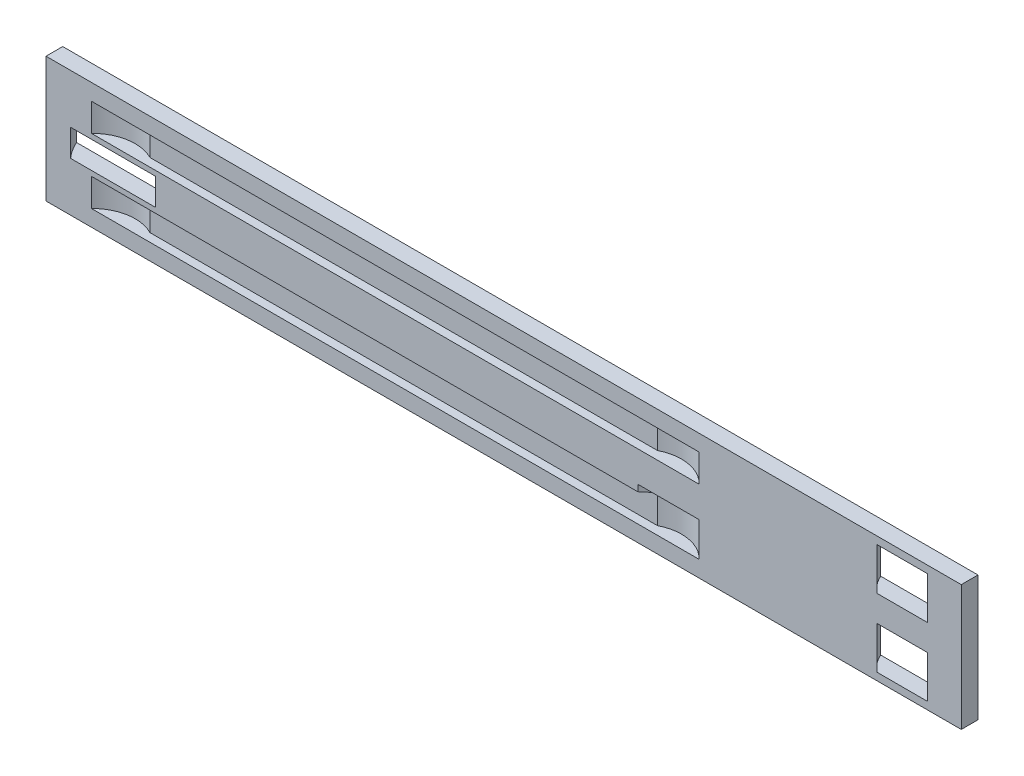
from build123d import *

# Parameters (mm, degrees)
CROQUIS1_W              = 985
CROQUIS1_H              = 135
SALIENTE_EXTRUIR1_DEPTH = 18
CROQUIS2_R              = 45
CORTAR_EXTRUIR1_DEPTH   = 45.5
CROQUIS4_R              = 62.2
CORTAR_EXTRUIR2_DEPTH   = 14.5
CORTAR_EXTRUIR3_DEPTH   = 15
CROQUIS7_R              = 46
CORTAR_EXTRUIR4_DEPTH   = 7


with BuildPart() as part:
    # Croquis1 → Saliente-Extruir1 (new body)
    with BuildSketch(Plane.XY):
        with Locations((492.5, 67.5)):
            Rectangle(CROQUIS1_W, CROQUIS1_H)
    extrude(amount=SALIENTE_EXTRUIR1_DEPTH)

    # Croquis2 → Cortar-Extruir1 (cut)
    with BuildSketch(Plane(origin=(0, 8, 0), x_dir=(-1, 0, 0), z_dir=(0, -1, 0))):
        with Locations((-921.5, 18)):
            Circle(CROQUIS2_R)
    cortar_extruir1 = extrude(amount=-CORTAR_EXTRUIR1_DEPTH, mode=Mode.SUBTRACT)

    # Simetría1: Cortar-Extruir1 across plane
    add(cortar_extruir1.mirror(Plane.ZX.offset(67.5)), mode=Mode.SUBTRACT)

    # Croquis4 → Cortar-Extruir2 (cut, symmetric)
    with BuildSketch(Plane(origin=(0, 67.5, 0), x_dir=(1, 0, 0), z_dir=(0, 1, 0))):
        with Locations((72.2, 24.2)):
            Circle(CROQUIS4_R)
    extrude(amount=CORTAR_EXTRUIR2_DEPTH, both=True, mode=Mode.SUBTRACT)

    # Croquis5 → Cortar-Extruir3 (cut, symmetric)
    with BuildSketch(Plane(origin=(0, 102.5, 0), x_dir=(1, 0, 0), z_dir=(0, 1, 0))):
        with BuildLine():
            Line((102.856653615, -9), (649.052499818, -9))
            ThreePointArc((649.052499818, -9), (677.48487297, -4.628109214), (702.954576716, -18))
            Line((702.954576716, -18), (48.954576716, -18))
            ThreePointArc((48.954576716, -18), (74.424280462, -4.628109214), (102.856653615, -9))
        make_face()
    cortar_extruir3 = extrude(amount=CORTAR_EXTRUIR3_DEPTH, both=True, mode=Mode.SUBTRACT)

    # Simetría5: Cortar-Extruir3 across plane
    add(cortar_extruir3.mirror(Plane.ZX.offset(67.5)), mode=Mode.SUBTRACT)

    # Croquis7 → Cortar-Extruir4 (cut)
    with BuildSketch(Plane.XZ.offset(-47.5)):
        with Locations((669.909153433, 50)):
            Circle(CROQUIS7_R)
    extrude(amount=-CORTAR_EXTRUIR4_DEPTH, mode=Mode.SUBTRACT)


solid = part.part
